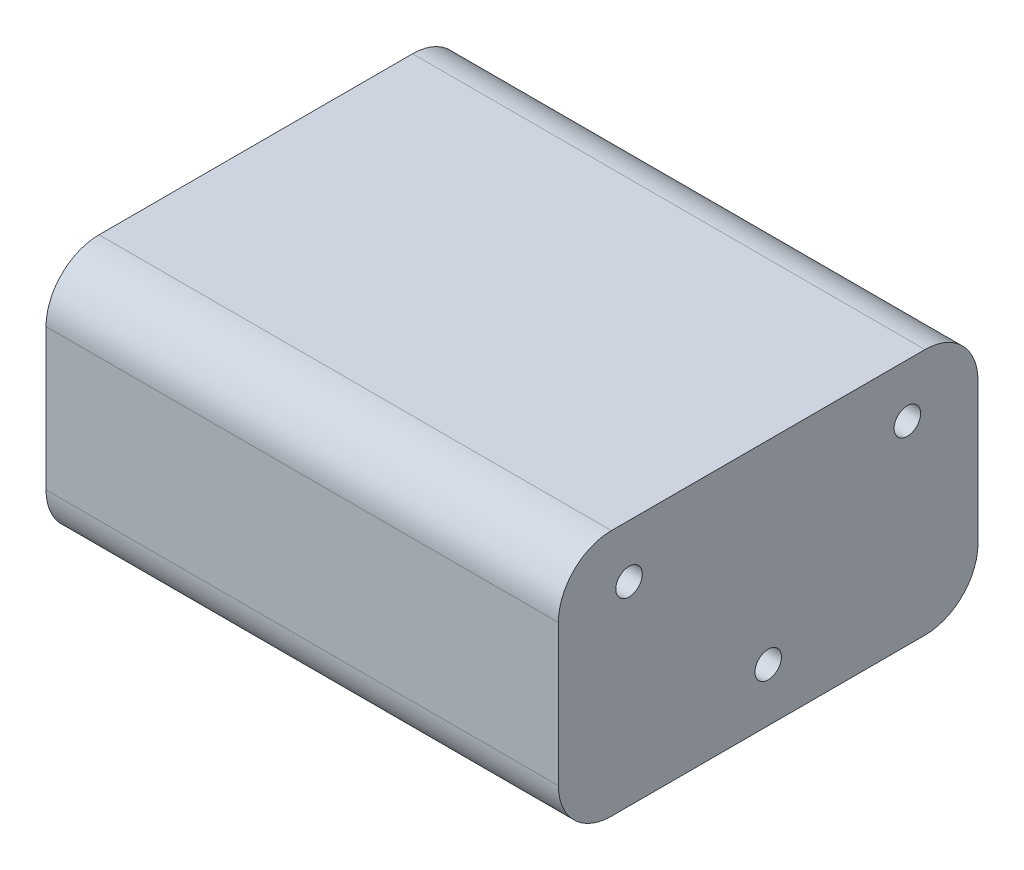
from build123d import *

# Parameters (mm, degrees)
SKETCH1_W           = 58
SKETCH1_H           = 47.5
BOSS_EXTRUDE1_DEPTH = 28
FILLET3_R           = 6
SKETCH2_R           = 1.5
CUT_EXTRUDE1_DEPTH  = 3
CUT_EXTRUDE2_START  = -29
SKETCH3_R           = 1.5
CUT_EXTRUDE2_DEPTH  = 3


with BuildPart() as part:
    # Sketch1 → Boss-Extrude1 (new body)
    with BuildSketch(Plane(origin=(0, 0, 0), x_dir=(1, 0, 0), z_dir=(0, 1, 0))):
        Rectangle(SKETCH1_W, SKETCH1_H)
    extrude(amount=BOSS_EXTRUDE1_DEPTH)

    # Fillet3
    fillet3_edges = [part.edges().sort_by_distance(p)[0] for p in [
        (0, 28, 23.75),
        (0, 0, 23.75),
        (0, 0, -23.75),
        (0, 28, -23.75),
    ]]
    fillet(fillet3_edges, radius=FILLET3_R)

    # Sketch2 → Cut-Extrude1 (cut)
    with BuildSketch(Plane(origin=(29, 0, 0), x_dir=(0, 0, -1), z_dir=(1, 0, 0))):
        with Locations((0, 6)):
            Circle(SKETCH2_R)
        with Locations((-15.75, 22)):
            Circle(SKETCH2_R)
        with Locations((15.75, 22)):
            Circle(SKETCH2_R)
    extrude(amount=-CUT_EXTRUDE1_DEPTH, mode=Mode.SUBTRACT)

    # Sketch3 → Cut-Extrude2 (cut)
    with BuildSketch(Plane(origin=(0, 0, 0), x_dir=(0, 0, -1), z_dir=(1, 0, 0)).offset(CUT_EXTRUDE2_START)):
        with Locations((0.107591006, 22)):
            Circle(SKETCH3_R)
        with Locations((-15.75, 6)):
            Circle(SKETCH3_R)
        with Locations((15.75, 6)):
            Circle(SKETCH3_R)
    extrude(amount=CUT_EXTRUDE2_DEPTH, mode=Mode.SUBTRACT)


solid = part.part
